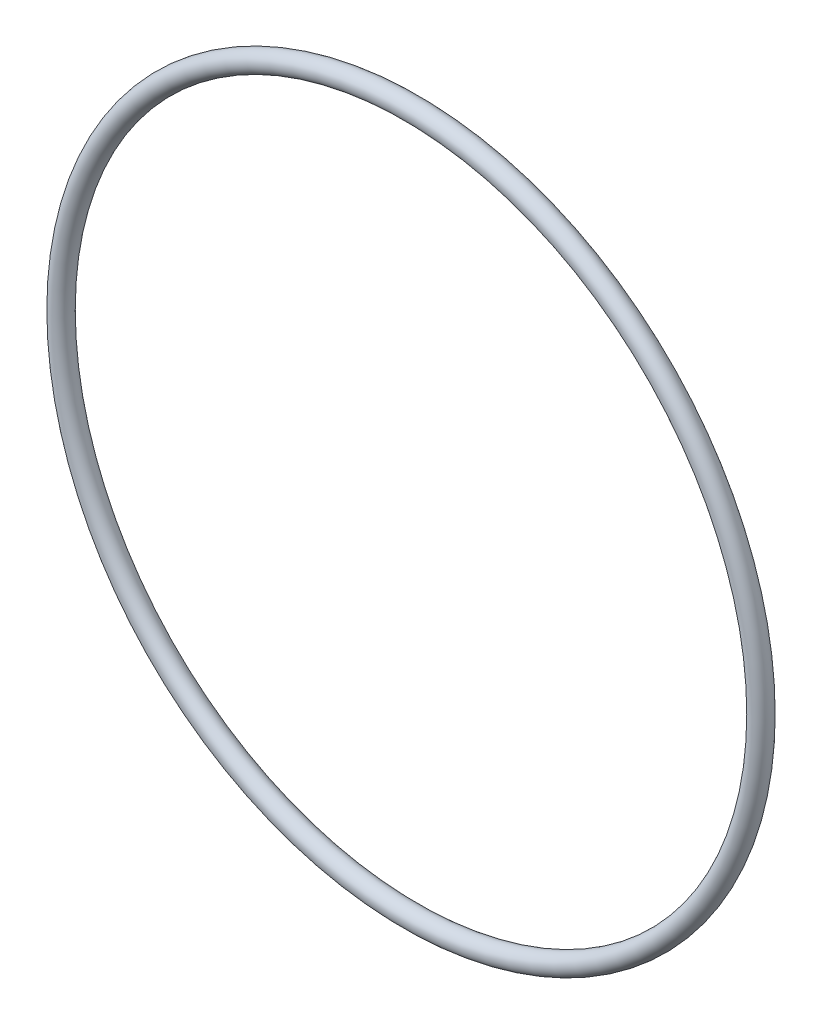
from build123d import *

# Parameters (mm, degrees)
BASE_SWEEP_PROFILE_R = 1.5875


with BuildPart() as part:
    # Base Sweep: sweep along a path in SketchPath
    with BuildLine(Plane.XY) as base_sweep_path:
        CenterArc((0, 0), 55.245, 0, 360)
    # Base Sweep profile (on start of the path) → Base Sweep (sweep)
    with BuildSketch(Plane(origin=(55.245, 0, 0), x_dir=(0, 0, 1), z_dir=(0, 1, 0))):
        Circle(BASE_SWEEP_PROFILE_R)
    sweep(path=base_sweep_path.line)


solid = part.part
